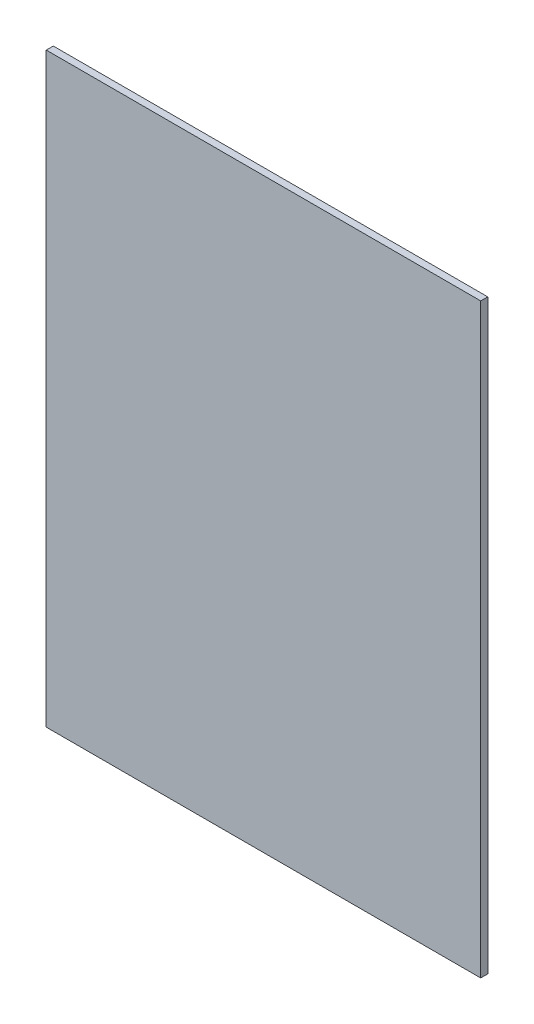
from build123d import *

# Parameters (mm, degrees)
SKETCH1_W           = 98.840202878
SKETCH1_H           = 133.40102225
BOSS_EXTRUDE1_DEPTH = 1.6


with BuildPart() as part:
    # Sketch1 → Boss-Extrude1 (new body)
    with BuildSketch(Plane.XY):
        with Locations((49.420101439, 66.700511125)):
            Rectangle(SKETCH1_W, SKETCH1_H)
    extrude(amount=BOSS_EXTRUDE1_DEPTH)


solid = part.part
